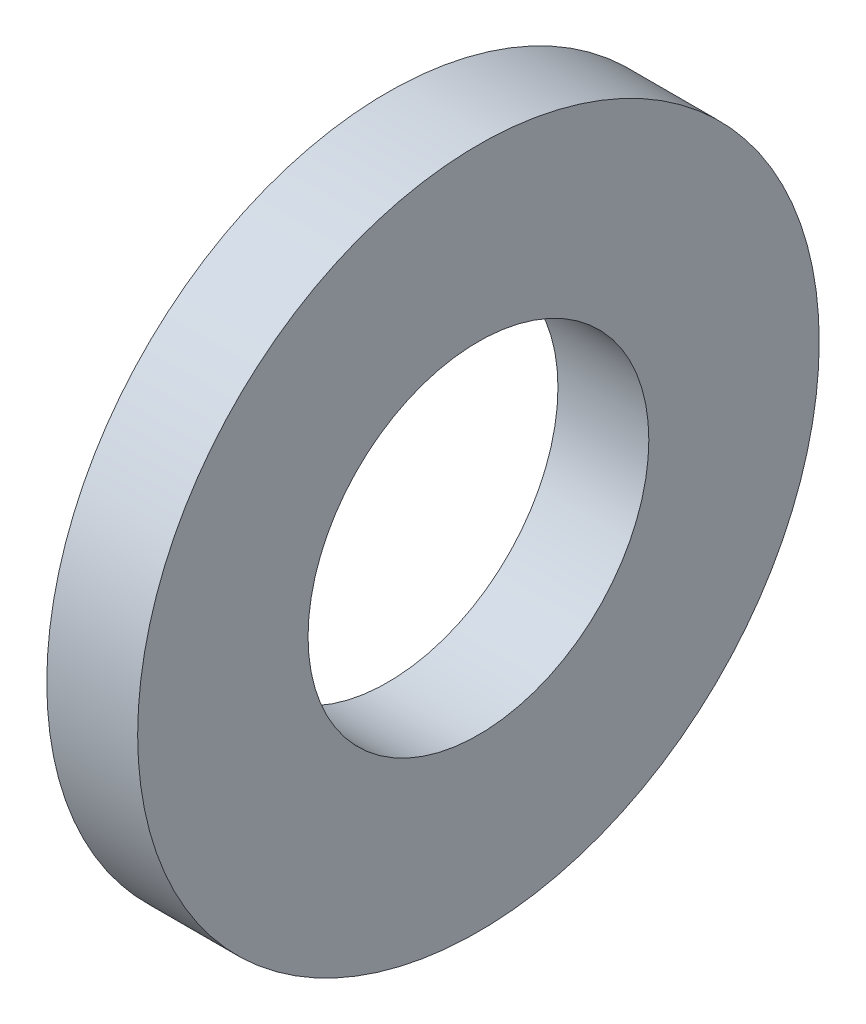
from build123d import *

# Parameters (mm, degrees)
ESQUISSE1_W = 2
ESQUISSE1_H = 3.75


with BuildPart() as part:
    # Esquisse1 → Révolution1 (revolve)
    with BuildSketch(Plane.XY, mode=Mode.PRIVATE) as r_volution1_sk:
        with Locations((-15.706392, 5.625)):
            Rectangle(ESQUISSE1_W, ESQUISSE1_H)
    revolve(r_volution1_sk.sketch.rotate(Axis((-42.630103093, 0, 0), (1, 0, 0)), 90), axis=Axis((-42.630103093, 0, 0), (1, 0, 0)))  # turned: the seam where the file's is


solid = part.part
